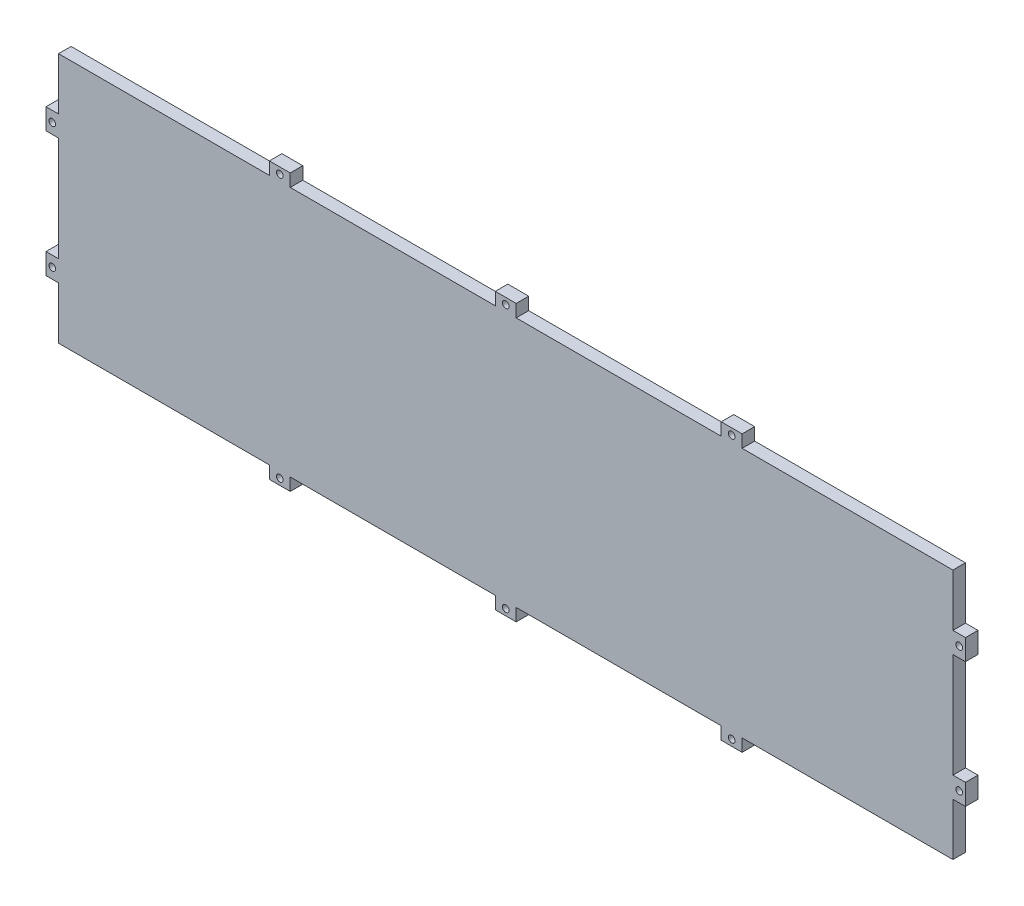
from build123d import *

# Parameters (mm, degrees)
SKETCH1_R           = 1.6
BOSS_EXTRUDE1_DEPTH = 6


with BuildPart() as part:
    # Sketch1 → Boss-Extrude1 (new body)
    with BuildSketch(Plane.XY):
        Polygon((6, 269), (106.875, 269), (106.875, 275), (116.875, 275), (116.875, 269), (215, 269), (215, 275), (225, 275), (225, 269), (323.125, 269), (323.125, 275), (333.125, 275), (333.125, 269), (434, 269), (434, 244), (440, 244), (440, 234), (434, 234), (434, 184), (440, 184), (440, 174), (434, 174), (434, 149), (333.125, 149), (333.125, 143), (323.125, 143), (323.125, 149), (225, 149), (225, 143), (215, 143), (215, 149), (116.875, 149), (116.875, 143), (106.875, 143), (106.875, 149), (6, 149), (6, 174), (0, 174), (0, 184), (6, 184), (6, 234), (0, 234), (0, 244), (6, 244), align=None)
        with Locations((111.875, 146)):
            Circle(SKETCH1_R, mode=Mode.SUBTRACT)
        with Locations((220, 146)):
            Circle(SKETCH1_R, mode=Mode.SUBTRACT)
        with Locations((328.125, 146)):
            Circle(SKETCH1_R, mode=Mode.SUBTRACT)
        with Locations((328.125, 272)):
            Circle(SKETCH1_R, mode=Mode.SUBTRACT)
        with Locations((220, 272)):
            Circle(SKETCH1_R, mode=Mode.SUBTRACT)
        with Locations((111.875, 272)):
            Circle(SKETCH1_R, mode=Mode.SUBTRACT)
        with Locations((3, 239)):
            Circle(SKETCH1_R, mode=Mode.SUBTRACT)
        with Locations((3, 179)):
            Circle(SKETCH1_R, mode=Mode.SUBTRACT)
        with Locations((437, 239)):
            Circle(SKETCH1_R, mode=Mode.SUBTRACT)
        with Locations((437, 179)):
            Circle(SKETCH1_R, mode=Mode.SUBTRACT)
    extrude(amount=-BOSS_EXTRUDE1_DEPTH)


solid = part.part
